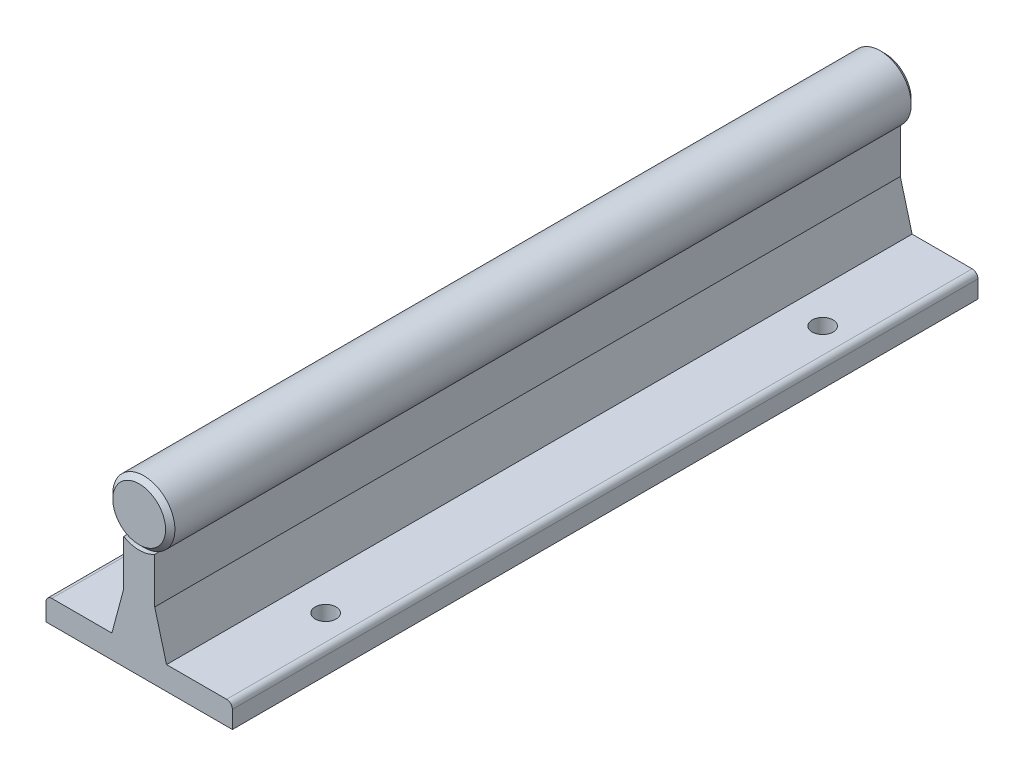
from build123d import *

# Parameters (mm, degrees)
EXTRUDE1_DEPTH  = 76.2
FILLET1_R       = 1.190625
SKETCH4_R       = 2.1463
EXTRUDE3_DEPTH  = 4.7625
LPATTERN1_COUNT = 19
LPATTERN1_PITCH = 101.6


with BuildPart() as part:
    # Sketch1 → Extrude1 (new body, symmetric)
    with BuildSketch(Plane.XY):
        with BuildLine():
            Line((-19.05, 0), (19.05, 0))
            Line((19.05, 0), (19.05, 4.7625))
            Line((19.05, 4.7625), (5.585983612, 4.7625))
            Line((5.585983612, 4.7625), (3.175, 13.760413336))
            Line((3.175, 13.760413336), (3.175, 23.075738686))
            ThreePointArc((3.175, 23.075738686), (0, 34.925), (-3.175, 23.075738686))
            Line((-3.175, 23.075738686), (-3.175, 13.760413336))
            Line((-3.175, 13.760413336), (-5.585983612, 4.7625))
            Line((-5.585983612, 4.7625), (-19.05, 4.7625))
            Line((-19.05, 4.7625), (-19.05, 0))
        make_face()
    extrude(amount=EXTRUDE1_DEPTH, both=True)

    # Sketch3 → Cut-Revolve1 (revolve, cut)
    with BuildSketch(Plane(origin=(0, 0, 0), x_dir=(0, 0, -1), z_dir=(1, 0, 0))):
        Polygon((-76.2, 33.9725), (-75.2475, 34.925), (-76.2, 34.925), align=None)
    cut_revolve1 = revolve(axis=Axis((0, 28.575, 76.2), (0, 0, -1)), mode=Mode.SUBTRACT)

    # Mirror1: Cut-Revolve1 across plane
    add(cut_revolve1.mirror(Plane.XY), mode=Mode.SUBTRACT)

    # Fillet1
    fillet1_edges = [part.edges().sort_by_distance(p)[0] for p in [
        (-19.05, 4.7625, 0),
        (19.05, 4.7625, 0),
    ]]
    fillet(fillet1_edges, radius=FILLET1_R)

    # Sketch4 → Extrude3 (cut)
    with BuildSketch(Plane(origin=(0, 0, 0), x_dir=(1, 0, 0), z_dir=(0, 1, 0))):
        with Locations((12.7, -50.8)):
            Circle(SKETCH4_R)
        with Locations((-12.7, -50.8)):
            Circle(SKETCH4_R)
    extrude3 = extrude(amount=EXTRUDE3_DEPTH, mode=Mode.SUBTRACT)

    # LPattern1: Extrude3 ×19
    with Locations(*[(0, 0, -i * LPATTERN1_PITCH) for i in range(1, LPATTERN1_COUNT)]):
        add(extrude3, mode=Mode.SUBTRACT)


solid = part.part
